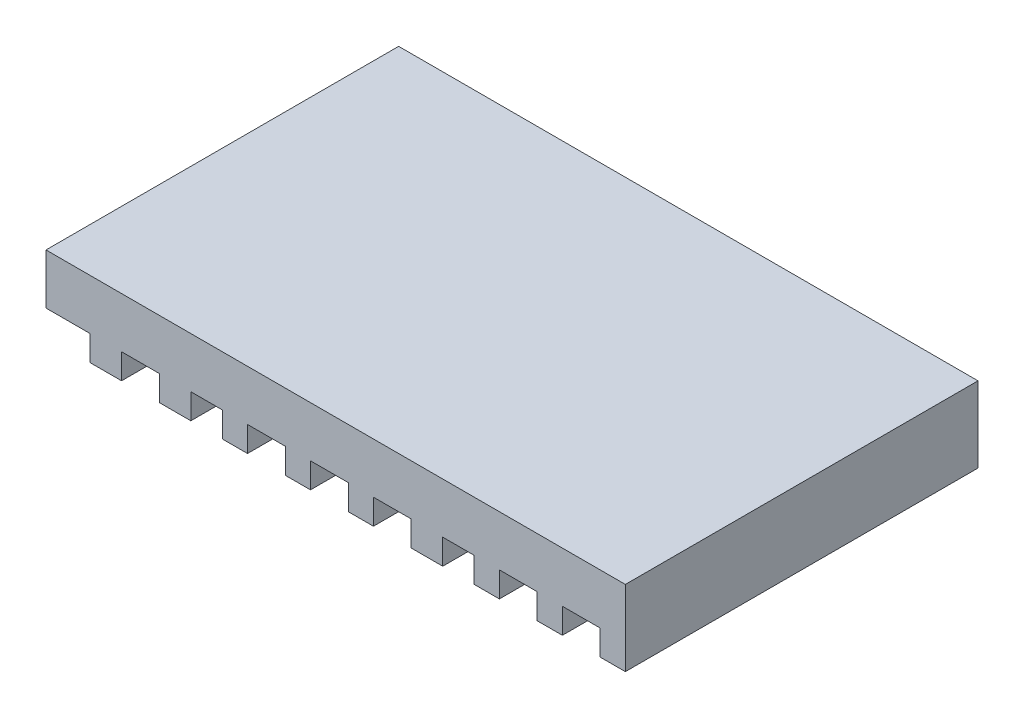
from build123d import *

# Parameters (mm, degrees)
BOSS_EXTRUDE1_DEPTH = 28


with BuildPart() as part:
    # Sketch1 → Boss-Extrude1 (new body)
    with BuildSketch(Plane.XY):
        Polygon((-23, -1.000000551), (-19.500008127, -1.000000551), (-19.500008127, -3), (-17.000007621, -3), (-17.000007621, -1.000000551), (-14.000005953, -1.000000551), (-14.000005953, -3), (-11.500005447, -3), (-11.500005447, -1.000000551), (-9.000004942, -1.000000551), (-9.000004942, -3), (-7.000005493, -3), (-7.000005493, -1.000000551), (-4.000003825, -1.000000551), (-4.000003825, -3), (-2.000004376, -3), (-2.000004376, -1.000000551), (0.999997292, -1.000000551), (0.999997292, -3), (2.99999674, -3), (2.99999674, -1.000000551), (5.999998408, -1.000000551), (5.999998408, -3), (8.499998914, -3), (8.499998914, -1.000000551), (10.99999942, -1.000000551), (10.99999942, -3), (12.999998868, -3), (12.999998868, -1.000000551), (16.000000536, -1.000000551), (16.000000536, -3), (17.999999985, -3), (17.999999985, -1.000000551), (21.000001653, -1.000000551), (21.000001653, -3), (23.000001102, -3), (23.000001102, 3), (-23, 3), align=None)
    extrude(amount=BOSS_EXTRUDE1_DEPTH)


solid = part.part
